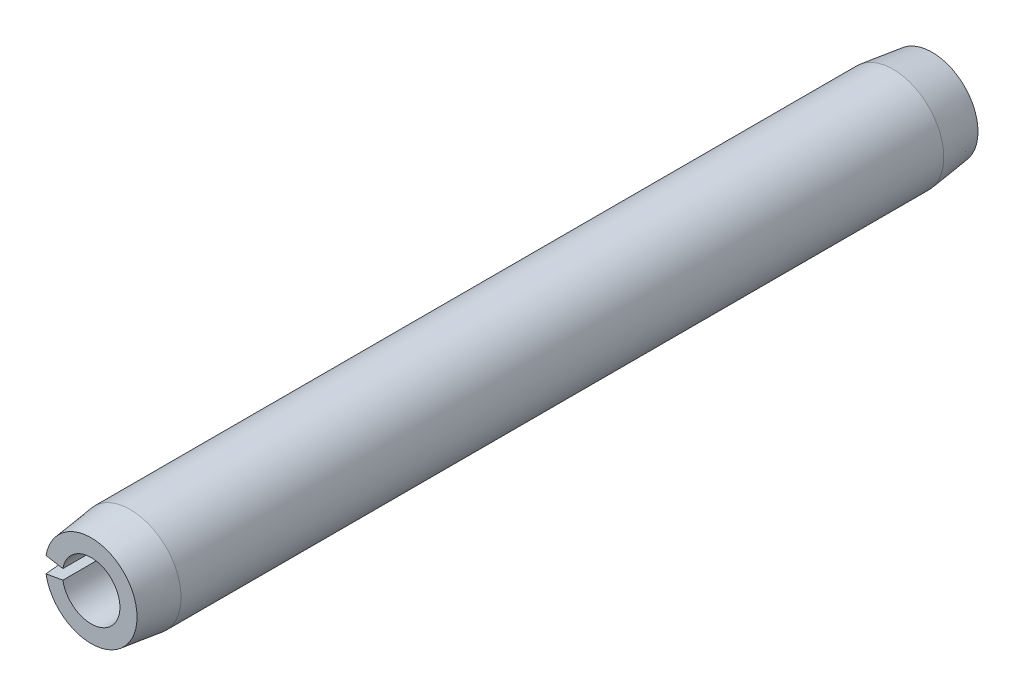
from build123d import *

# Parameters (mm, degrees)
EXTRUDE1_DEPTH = 8.73125


with BuildPart() as part:
    # Sketch1 → Extrude1 (new body, symmetric)
    with BuildSketch(Plane.XY):
        with BuildLine():
            Line((-1.038085852, 0.183042544), (-0.587831748, 0.103650597))
            ThreePointArc((-0.587831748, 0.103650597), (0.5969, 0), (-0.587831748, -0.103650597))
            Line((-0.587831748, -0.103650597), (-1.038085852, -0.183042544))
            ThreePointArc((-1.038085852, -0.183042544), (1.0541, 0), (-1.038085852, 0.183042544))
        make_face()
    extrude(amount=EXTRUDE1_DEPTH, both=True)

    # Sketch2 → Cut-Revolve1 (revolve, cut)
    with BuildSketch(Plane(origin=(0, 0, 0), x_dir=(0, 0, -1), z_dir=(1, 0, 0))):
        Polygon((8.73125, 1.0541), (8.73125, 0.9525), (7.91845, 1.0541), align=None)
        Polygon((-7.91845, 1.0541), (-8.73125, 1.0541), (-8.73125, 0.9525), align=None)
    revolve(axis=Axis((0, 0, -8.73125), (0, 0, 1)), mode=Mode.SUBTRACT)


solid = part.part
